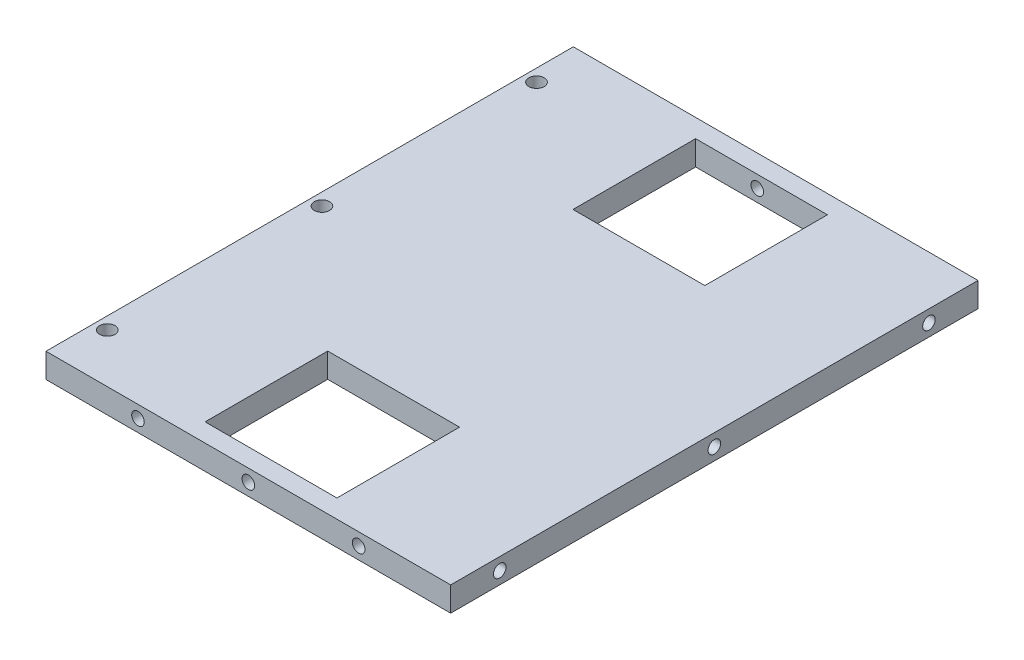
from build123d import *

# Parameters (mm, degrees)
SKETCH_1_R                    = 1.25
EXTRUDE_1_DEPTH               = 4
SKETCH_2_W                    = 21.5
SKETCH_2_H                    = 20
CUT_EXTRUDE_1_DEPTH           = 8
HOLE_WIZARD_M2_5_1_AT_2_COUNT = 2
HOLE_WIZARD_M2_5_1_AT_2_PITCH = 18
HOLE_WIZARD_M2_5_1_AT_3_COUNT = 2
HOLE_WIZARD_M2_5_1_AT_3_PITCH = 36
HOLE_WIZARD_M2_5_2_D          = 2.05
HOLE_WIZARD_M2_5_2_DEPTH      = 7.25
HOLE_WIZARD_M2_5_2_TIP        = 0.615882135


with BuildPart() as part:
    # 草图1 → 凸台-拉伸1 (new body)
    with BuildSketch(Plane(origin=(0, 0, 0), x_dir=(1, 0, 0), z_dir=(0, 1, 0))):
        Polygon((0, 0), (0, 43), (66, 43), (66, -43), (0, -43), align=None)
        with Locations((2, 0)):
            Circle(SKETCH_1_R, mode=Mode.SUBTRACT)
        with Locations((2, 35)):
            Circle(SKETCH_1_R, mode=Mode.SUBTRACT)
        with Locations((2, -35)):
            Circle(SKETCH_1_R, mode=Mode.SUBTRACT)
    extrude(amount=EXTRUDE_1_DEPTH)

    # 草图2 → 切除-拉伸1 (cut)
    with BuildSketch(Plane(origin=(0, 0, 0), x_dir=(1, 0, 0), z_dir=(0, 1, 0))):
        with Locations((33.697153025, -30)):
            Rectangle(SKETCH_2_W, SKETCH_2_H)
        with Locations((33.697153025, 30)):
            Rectangle(SKETCH_2_W, SKETCH_2_H)
    extrude(amount=CUT_EXTRUDE_1_DEPTH, mode=Mode.SUBTRACT)

    # 草图6 → M2.5 螺纹孔1 (revolve, cut)
    with BuildSketch(Plane(origin=(15, 2, 43), x_dir=(0, -1, 0), z_dir=(1, 0, 0))):
        Polygon((0, 0), (0, 8.865882135), (1.025, 8.25), (1.025, 0), align=None)
    hole_wizard_m2_5_1 = revolve(axis=Axis((15, 2, 49.35), (0, 0, -1)), mode=Mode.SUBTRACT)

    # M2.5 螺纹孔1 at 2: M2.5 螺纹孔1 ×2
    with Locations(*[(i * HOLE_WIZARD_M2_5_1_AT_2_PITCH, 0, 0) for i in range(1, HOLE_WIZARD_M2_5_1_AT_2_COUNT)]):
        add(hole_wizard_m2_5_1, mode=Mode.SUBTRACT)

    # M2.5 螺纹孔1 at 3: M2.5 螺纹孔1 ×2
    with Locations(*[(i * HOLE_WIZARD_M2_5_1_AT_3_PITCH, 0, 0) for i in range(1, HOLE_WIZARD_M2_5_1_AT_3_COUNT)]):
        add(hole_wizard_m2_5_1, mode=Mode.SUBTRACT)

    # 镜向1: M2.5 螺纹孔1 across plane
    add(hole_wizard_m2_5_1.mirror(Plane.XY), mode=Mode.SUBTRACT)

    # 镜向1 copy 1 sketch → 镜向1 copy 1 (revolve, cut)
    with BuildSketch(Plane(origin=(33, 2, -43), x_dir=(0, -1, 0), z_dir=(1, 0, 0))):
        Polygon((0, 0), (0, -8.865882135), (1.025, -8.25), (1.025, 0), align=None)
    revolve(axis=Axis((33, 2, -49.35), (0, 0, -1)), mode=Mode.SUBTRACT)

    # 镜向1 copy 2 sketch → 镜向1 copy 2 (revolve, cut)
    with BuildSketch(Plane(origin=(51, 2, -43), x_dir=(0, -1, 0), z_dir=(1, 0, 0))):
        Polygon((0, 0), (0, -8.865882135), (1.025, -8.25), (1.025, 0), align=None)
    revolve(axis=Axis((51, 2, -49.35), (0, 0, -1)), mode=Mode.SUBTRACT)

    # M2.5 螺纹孔2
    with Locations(Plane(origin=(66, 0, 0), x_dir=(0, 0, -1), z_dir=(1, 0, 0))):
        with Locations((0, 2), (-35, 2), (35, 2)):
            Hole(HOLE_WIZARD_M2_5_2_D / 2, depth=HOLE_WIZARD_M2_5_2_DEPTH)
            with Locations((0, 0, -(HOLE_WIZARD_M2_5_2_DEPTH + HOLE_WIZARD_M2_5_2_TIP / 2))):  # 118° drill point
                Cone(0, HOLE_WIZARD_M2_5_2_D / 2, HOLE_WIZARD_M2_5_2_TIP, mode=Mode.SUBTRACT)


solid = part.part
